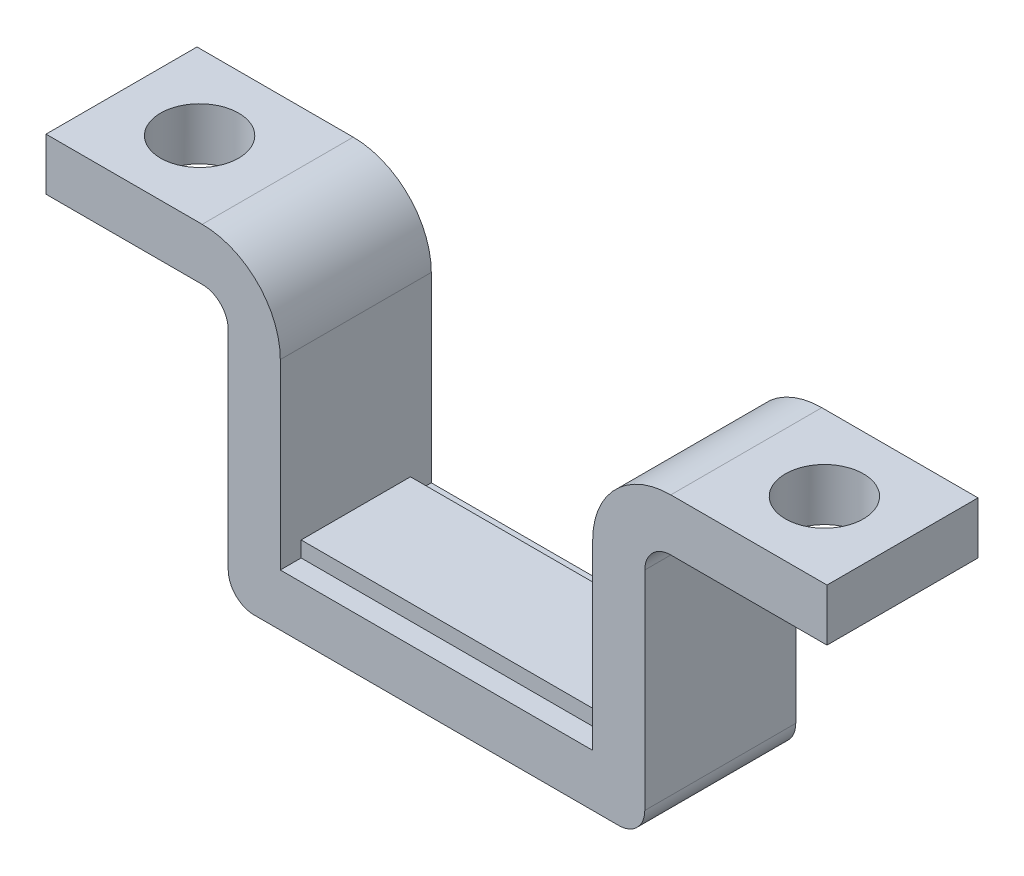
from build123d import *

# Parameters (mm, degrees)
BOSS_EXTRUDE1_DEPTH = 2.9
SKETCH4_W           = 12
SKETCH4_H           = 0.6
BOSS_EXTRUDE2_DEPTH = 2.1
SKETCH5_R           = 1.5
CUT_EXTRUDE1_DEPTH  = 13


with BuildPart() as part:
    # Sketch3 → Boss-Extrude1 (new body, symmetric)
    with BuildSketch(Plane.XY):
        with BuildLine():
            Line((-6, -5), (6, -5))
            Line((6, -5), (6, 2))
            ThreePointArc((6, 2), (6.878679656, 4.121320344), (9, 5))
            Line((9, 5), (15, 5))
            Line((15, 5), (15, 3))
            Line((15, 3), (9, 3))
            ThreePointArc((9, 3), (8.292893219, 2.707106781), (8, 2))
            Line((8, 2), (8, -6))
            ThreePointArc((8, -6), (7.707106781, -6.707106781), (7, -7))
            Line((7, -7), (-7, -7))
            ThreePointArc((-7, -7), (-7.707106781, -6.707106781), (-8, -6))
            Line((-8, -6), (-8, 2))
            ThreePointArc((-8, 2), (-8.292893219, 2.707106781), (-9, 3))
            Line((-9, 3), (-15, 3))
            Line((-15, 3), (-15, 5))
            Line((-15, 5), (-9, 5))
            ThreePointArc((-9, 5), (-6.878679656, 4.121320344), (-6, 2))
            Line((-6, 2), (-6, -5))
        make_face()
    extrude(amount=BOSS_EXTRUDE1_DEPTH, both=True)

    # Sketch4 → Boss-Extrude2 (add, symmetric)
    with BuildSketch(Plane.XY):
        with Locations((0, -4.7)):
            Rectangle(SKETCH4_W, SKETCH4_H)
    extrude(amount=BOSS_EXTRUDE2_DEPTH, both=True)

    # Sketch5 → Cut-Extrude1 (cut, through all)
    with BuildSketch(Plane(origin=(0, 5, 0), x_dir=(1, 0, 0), z_dir=(0, 1, 0))):
        with Locations((12, 0)):
            Circle(SKETCH5_R)
        with Locations((-12, 0)):
            Circle(SKETCH5_R)
    extrude(amount=-CUT_EXTRUDE1_DEPTH, mode=Mode.SUBTRACT)


solid = part.part
